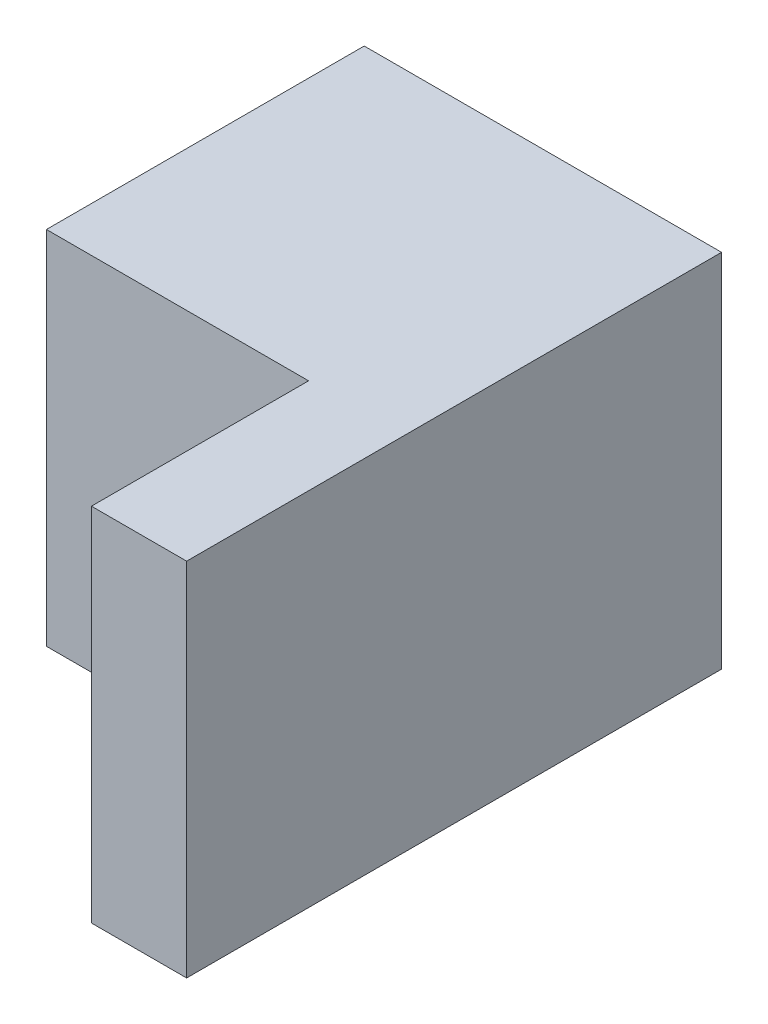
from build123d import *

# Parameters (mm, degrees)
SKETCH1_W           = 67.469915498
SKETCH1_H           = 68.163099562
BOSS_EXTRUDE1_DEPTH = 60
SKETCH2_W           = 17.975371397
SKETCH2_H           = 68.163099562
BOSS_EXTRUDE2_DEPTH = 41


with BuildPart() as part:
    # Sketch1 → Boss-Extrude1 (new body)
    with BuildSketch(Plane.XY):
        Rectangle(SKETCH1_W, SKETCH1_H)
    extrude(amount=BOSS_EXTRUDE1_DEPTH)

    # Sketch2 → Boss-Extrude2 (add)
    with BuildSketch(Plane.XY.offset(60)):
        with Locations((24.747272051, 0)):
            Rectangle(SKETCH2_W, SKETCH2_H)
    extrude(amount=BOSS_EXTRUDE2_DEPTH)


solid = part.part
